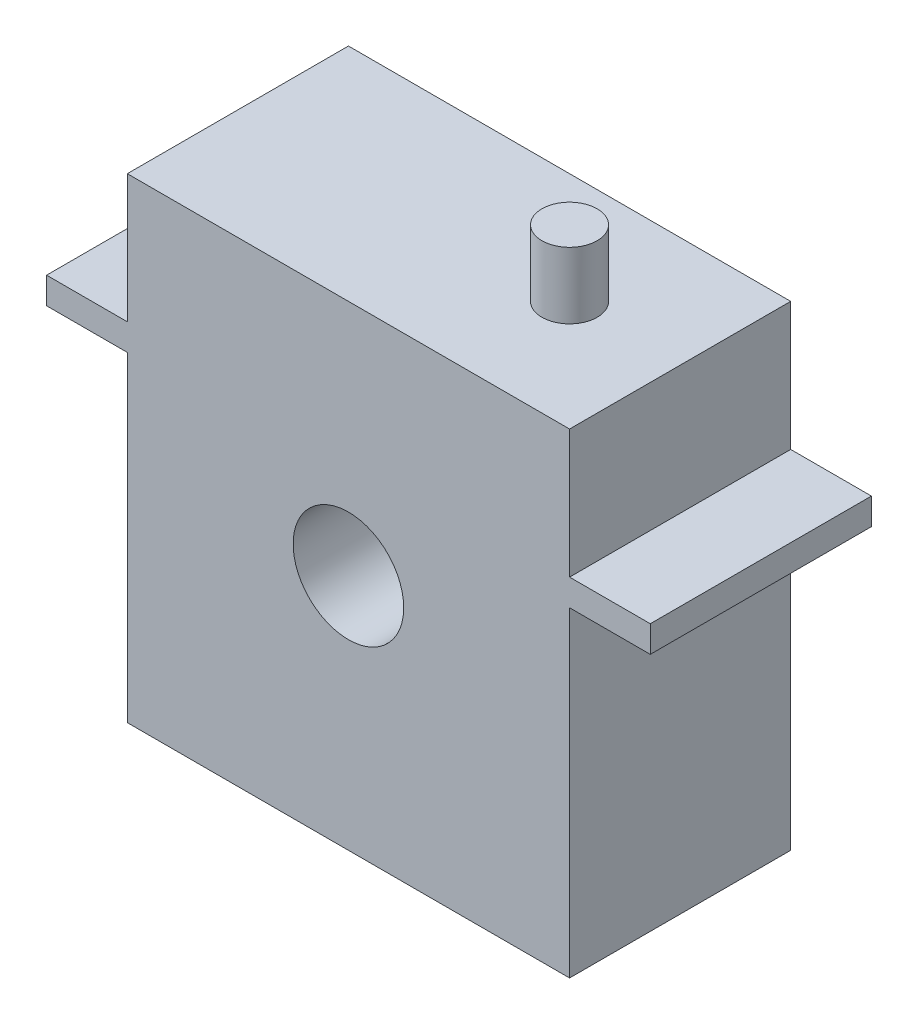
from build123d import *

# Parameters (mm, degrees)
SKETCH1_W           = 40
SKETCH1_H           = 43
SKETCH1_R           = 5
BOSS_EXTRUDE1_DEPTH = 20
SKETCH2_R           = 2.5
BOSS_EXTRUDE2_DEPTH = 6
SKETCH3_W           = 20
SKETCH3_H           = 2.4
BOSS_EXTRUDE3_DEPTH = 7.3


with BuildPart() as part:
    # Sketch1 → Boss-Extrude1 (new body)
    with BuildSketch(Plane.XY):
        Rectangle(SKETCH1_W, SKETCH1_H)
        Circle(SKETCH1_R, mode=Mode.SUBTRACT)
    extrude(amount=BOSS_EXTRUDE1_DEPTH)

    # Sketch2 → Boss-Extrude2 (add)
    with BuildSketch(Plane(origin=(0, 21.5, 0), x_dir=(1, 0, 0), z_dir=(0, 1, 0))):
        with Locations((10, -10)):
            Circle(SKETCH2_R)
    extrude(amount=BOSS_EXTRUDE2_DEPTH)

    # Sketch3 → Boss-Extrude3 (add)
    with BuildSketch(Plane.ZY.offset(20)):
        with Locations((10, 8.7)):
            Rectangle(SKETCH3_W, SKETCH3_H)
    boss_extrude3 = extrude(amount=BOSS_EXTRUDE3_DEPTH)

    # Mirror1: Boss-Extrude3 across plane
    add(boss_extrude3.mirror(Plane(origin=(0, 0, 0), x_dir=(0, 0, 1), z_dir=(1, 0, 0))))


solid = part.part
